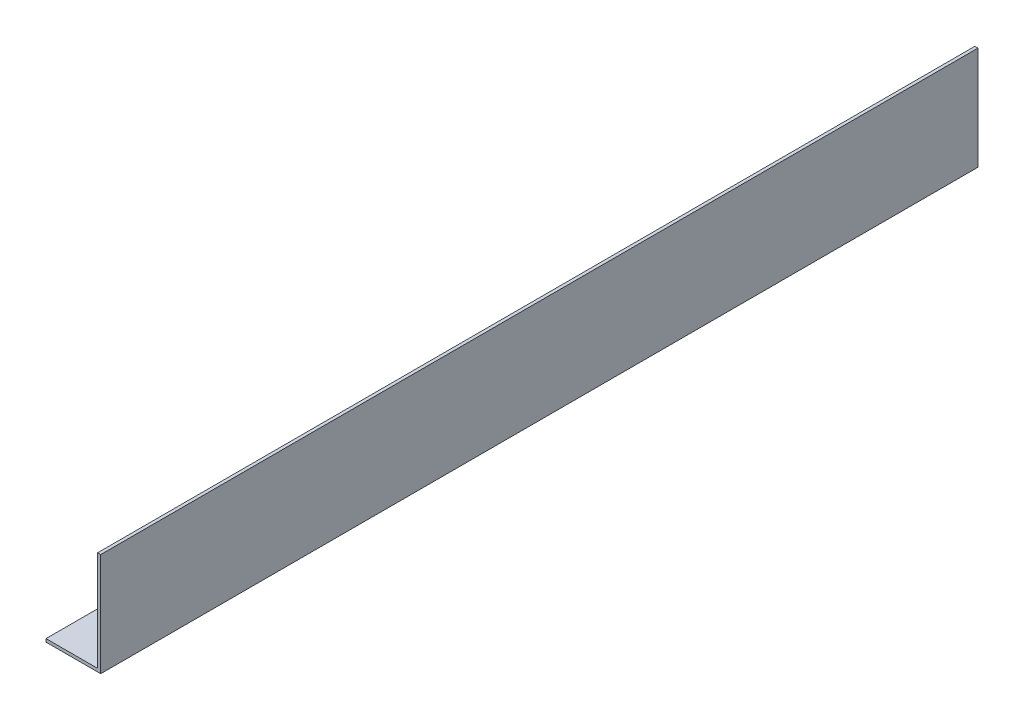
from build123d import *

# Parameters (mm, degrees)
BOSS_EXTRUDE2_DEPTH = 431.8


with BuildPart() as part:
    # Sketch3 → Boss-Extrude2 (new body)
    with BuildSketch(Plane.XY):
        Polygon((0, 0), (-26.924, 0), (-26.924, 1.524), (-1.524, 1.524), (-1.524, 50.8), (0, 50.8), align=None)
    extrude(amount=BOSS_EXTRUDE2_DEPTH)


solid = part.part
